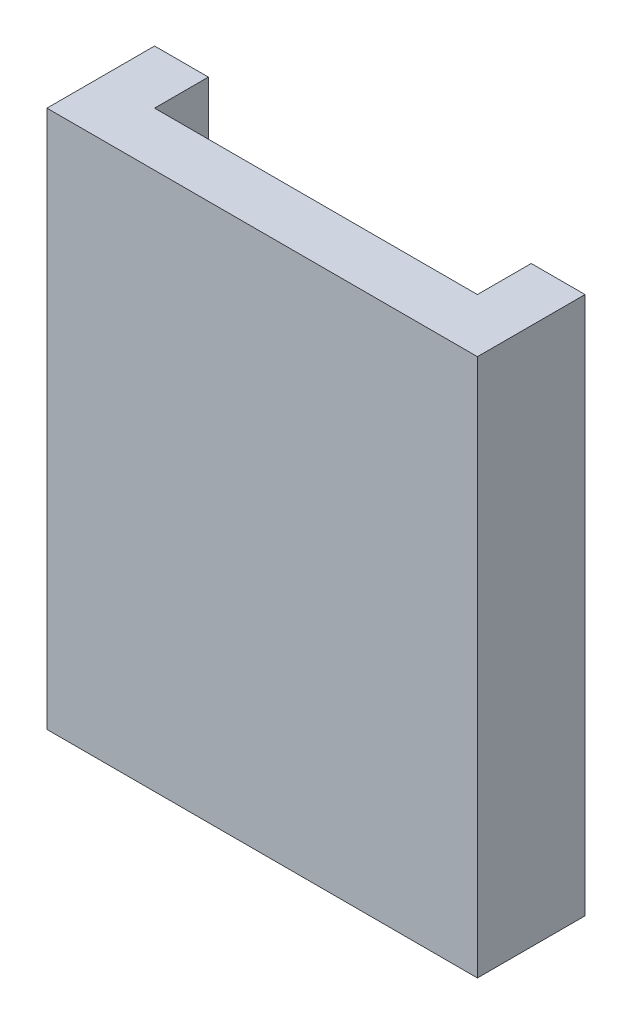
from build123d import *

# Parameters (mm, degrees)
SKETCH1_W           = 80
SKETCH1_H           = 100
BOSS_EXTRUDE1_DEPTH = 20
SKETCH2_W           = 60
SKETCH2_H           = 10
CUT_EXTRUDE1_DEPTH  = 100


with BuildPart() as part:
    # Sketch1 → Boss-Extrude1 (new body)
    with BuildSketch(Plane.XY):
        Rectangle(SKETCH1_W, SKETCH1_H)
    extrude(amount=BOSS_EXTRUDE1_DEPTH)

    # Sketch2 → Cut-Extrude1 (cut)
    with BuildSketch(Plane(origin=(0, 50, 0), x_dir=(1, 0, 0), z_dir=(0, 1, 0))):
        with Locations((0, -5)):
            Rectangle(SKETCH2_W, SKETCH2_H)
    extrude(amount=-CUT_EXTRUDE1_DEPTH, mode=Mode.SUBTRACT)


solid = part.part
